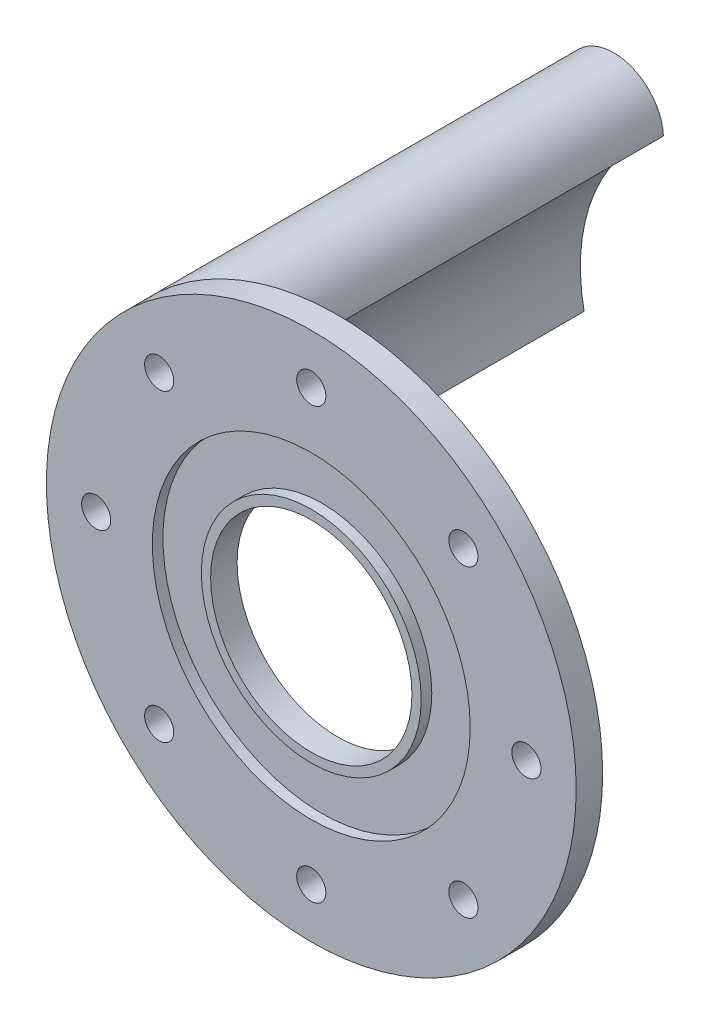
from build123d import *

# Parameters (mm, degrees)
CROQUIS1_R              = 50
CROQUIS1_R_2            = 19
SALIENTE_EXTRUIR1_DEPTH = 5
CROQUIS4_R              = 30
CROQUIS4_R_2            = 20.75
CORTAR_EXTRUIR1_DEPTH   = 2
CROQUIS5_R              = 2.75
CORTAR_EXTRUIR2_DEPTH   = 5
CROQUIS8_R              = 3.5
SALIENTE_EXTRUIR2_DEPTH = 80.8
CORTAR_EXTRUIR3_DEPTH   = 11
CORTAR_EXTRUIR4_DEPTH   = 19
CORTAR_EXTRUIR5_DEPTH   = 80.8


with BuildPart() as part:
    # Croquis1 → Saliente-Extruir1 (new body)
    with BuildSketch(Plane.XY):
        Circle(CROQUIS1_R)
        Circle(CROQUIS1_R_2, mode=Mode.SUBTRACT)
    extrude(amount=SALIENTE_EXTRUIR1_DEPTH)

    # Croquis4 → Cortar-Extruir1 (cut)
    with BuildSketch(Plane.XY.offset(5)):
        Circle(CROQUIS4_R)
        Circle(CROQUIS4_R_2, mode=Mode.SUBTRACT)
    extrude(amount=-CORTAR_EXTRUIR1_DEPTH, mode=Mode.SUBTRACT)

    # Croquis5 → Cortar-Extruir2 (cut)
    with BuildSketch(Plane.XY.offset(5)):
        with Locations((40.602997929, 0)):
            Circle(CROQUIS5_R)
        with Locations((28.710655172, -28.710655172)):
            Circle(CROQUIS5_R)
        with Locations((0, -40.602997929)):
            Circle(CROQUIS5_R)
        with Locations((-28.710655172, -28.710655172)):
            Circle(CROQUIS5_R)
        with Locations((-40.602997929, 0)):
            Circle(CROQUIS5_R)
        with Locations((-28.710655172, 28.710655172)):
            Circle(CROQUIS5_R)
        with Locations((0, 40.602997929)):
            Circle(CROQUIS5_R)
        with Locations((28.710655172, 28.710655172)):
            Circle(CROQUIS5_R)
    extrude(amount=-CORTAR_EXTRUIR2_DEPTH, mode=Mode.SUBTRACT)


with BuildPart() as body_2:
    # Croquis8 → Saliente-Extruir2 (new body)
    with BuildSketch(Plane(origin=(0, 0, 0), x_dir=(-1, 0, 0), z_dir=(0, 0, -1))):
        with BuildLine():
            ThreePointArc((34.299188914, -6.96890521), (32.335783638, 13.393920133), (19.325428939, 29.180949202))
            ThreePointArc((19.325428939, 29.180949202), (25.333020554, 37.479647834), (35.355339059, 35.355339059))
            ThreePointArc((35.355339059, 35.355339059), (46.193976626, 19.134171618), (50, 0))
            ThreePointArc((50, 0), (44.415263761, -8.588962518), (34.299188914, -6.96890521))
        make_face()
        with Locations((28.710655172, 28.710655172)):
            Circle(CROQUIS8_R, mode=Mode.SUBTRACT)
        with Locations((40.602997929, 0)):
            Circle(CROQUIS8_R, mode=Mode.SUBTRACT)
    extrude(amount=SALIENTE_EXTRUIR2_DEPTH)

    # Croquis9 → Cortar-Extruir3 (cut)
    with BuildSketch(Plane.XY):
        Polygon((-40.602997929, 4.907477288), (-44.852997929, 2.453738644), (-44.852997929, -2.453738644), (-40.602997929, -4.907477288), (-36.352997929, -2.453738644), (-36.352997929, 2.453738644), align=None)
        Polygon((-23.944605203, 27.540996663), (-25.314676205, 32.253346266), (-30.080726173, 33.423004776), (-33.476705141, 29.880313682), (-32.10663414, 25.167964078), (-27.340584171, 23.998305569), align=None)
    extrude(amount=-CORTAR_EXTRUIR3_DEPTH, mode=Mode.SUBTRACT)

    # Croquis10 → Cortar-Extruir4 (cut)
    with BuildSketch(Plane(origin=(0, 0, -80.8), x_dir=(-1, 0, 0), z_dir=(0, 0, -1))):
        Polygon((27.531125839, 23.947038491), (32.246303566, 25.307344465), (33.425832898, 30.070961146), (29.890184505, 33.474271853), (25.175006779, 32.11396588), (23.995477446, 27.350349198), align=None)
        Polygon((40.602997929, -4.907477288), (44.852997929, -2.453738644), (44.852997929, 2.453738644), (40.602997929, 4.907477288), (36.352997929, 2.453738644), (36.352997929, -2.453738644), align=None)
    extrude(amount=-CORTAR_EXTRUIR4_DEPTH, mode=Mode.SUBTRACT)

    # Croquis13 → Cortar-Extruir5 (cut)
    with BuildSketch(Plane.XY):
        with BuildLine():
            ThreePointArc((-44.852997929, 4.453738644), (-41.879481545, 17.236692785), (-35.064212145, 28.452655483))
            Line((-35.064212145, 28.452655483), (-33.533462291, 23.79002337))
            Line((-33.533462291, 23.79002337), (-28.730129506, 22.784375575))
            ThreePointArc((-28.730129506, 22.784375575), (-33.541663712, 14.034952678), (-36.352997929, 4.453738644))
            Line((-36.352997929, 4.453738644), (-40.602997929, 6.907477288))
            Line((-40.602997929, 6.907477288), (-44.852997929, 4.453738644))
        make_face()
    extrude(amount=-CORTAR_EXTRUIR5_DEPTH, mode=Mode.SUBTRACT)


solid = Compound([part.part, body_2.part])
